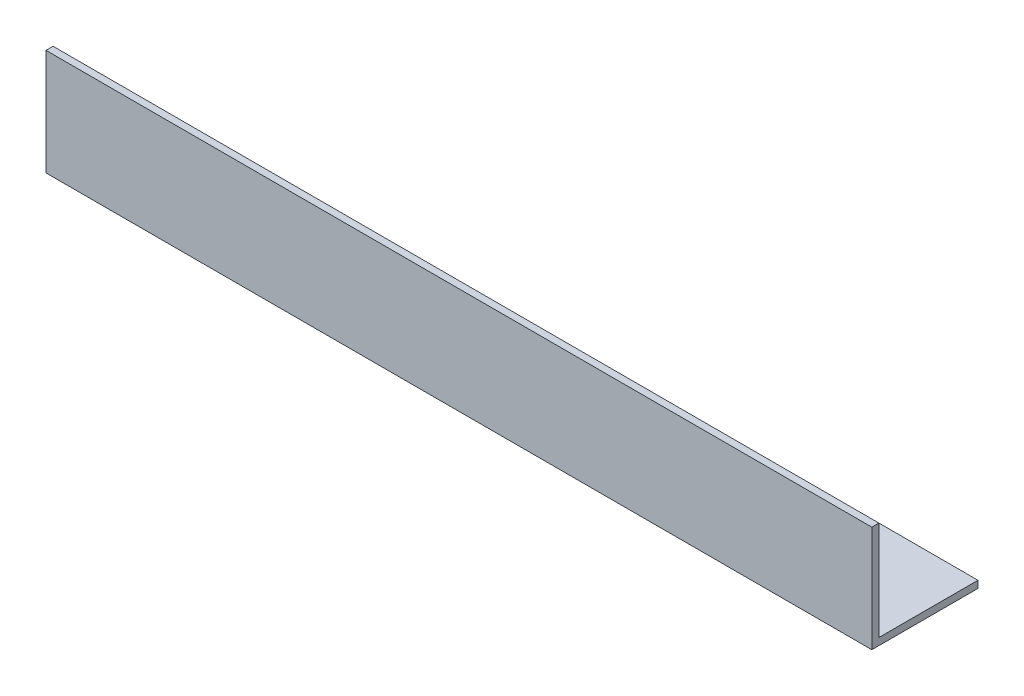
from build123d import *

# Parameters (mm, degrees)
EXTRUDE_1_DEPTH = 350


with BuildPart() as part:
    # Эскиз1 → Вытянуть-Тонкостенный1 (new body)
    with BuildSketch(Plane(origin=(0, 0, 0), x_dir=(0, 0, -1), z_dir=(1, 0, 0))):
        Polygon((45, 0), (0, 0), (0, 45), (3, 45), (3, 3), (45, 3), align=None)
    extrude(amount=EXTRUDE_1_DEPTH)


solid = part.part
